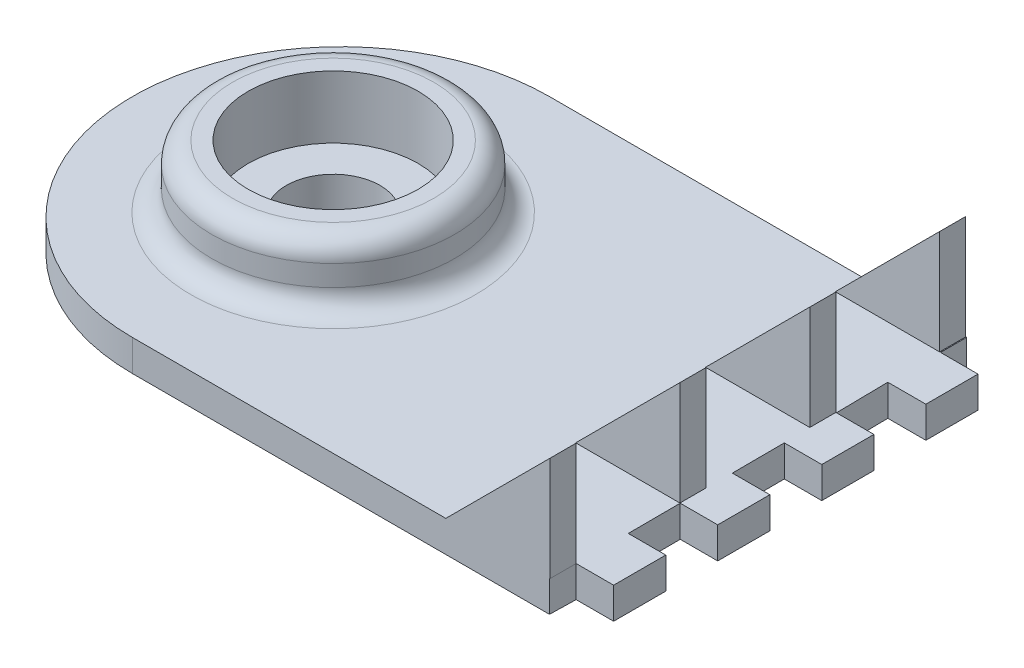
from build123d import *

# Parameters (mm, degrees)
BOSS_EXTRUDE1_DEPTH = 3
BOSS_EXTRUDE3_DEPTH = 2.5
LPATTERN2_COUNT     = 4
LPATTERN2_PITCH     = 12.5
SKETCH3_R           = 11.65
SKETCH3_R_2         = 8.15
BOSS_EXTRUDE4_DEPTH = 6
SKETCH4_R           = 4.5
CUT_EXTRUDE2_DEPTH  = 14
FILLET1_R           = 2
FILLET2_R           = 2


with BuildPart() as part:
    # Sketch1 → Boss-Extrude1 (new body)
    with BuildSketch(Plane(origin=(0, 0, 0), x_dir=(1, 0, 0), z_dir=(0, 1, 0))):
        with BuildLine():
            Line((20, 17.5), (23.592842073, 17.5))
            Line((23.592842073, 17.5), (23.592842073, 12.5))
            Line((23.592842073, 12.5), (19.944472227, 12.5))
            Line((19.944472227, 12.5), (20.019420438, 7.500018858))
            Line((20.019420438, 7.500018858), (23.612262511, 7.500018858))
            Line((23.612262511, 7.500018858), (23.612262511, 2.500018858))
            Line((23.612262511, 2.500018858), (20.019420438, 2.500018858))
            Line((20.019420438, 2.500018858), (20.038840876, -2.499962285))
            Line((20.038840876, -2.499962285), (23.63168295, -2.499962285))
            Line((23.63168295, -2.499962285), (23.63168295, -7.499962285))
            Line((23.63168295, -7.499962285), (20.038840876, -7.499962285))
            Line((20.038840876, -7.499962285), (20.058261315, -12.499943427))
            Line((20.058261315, -12.499943427), (23.651103388, -12.499943427))
            Line((23.651103388, -12.499943427), (23.651103388, -17.499943427))
            Line((23.651103388, -17.499943427), (20.058261315, -17.499943427))
            Line((20.058261315, -17.499943427), (20, -20))
            Line((20, -20), (-20, -20))
            ThreePointArc((-20, -20), (-40, 0), (-20, 20))
            Line((-20, 20), (20, 20))
            Line((20, 20), (20, 17.5))
        make_face()
    extrude(amount=BOSS_EXTRUDE1_DEPTH)

    # Sketch2 → Boss-Extrude3 (add)
    with BuildSketch(Plane.XY.offset(20)):
        Polygon((20.058261315, 3), (20.058261315, 13), (10.058261315, 3), align=None)
    boss_extrude3 = extrude(amount=-BOSS_EXTRUDE3_DEPTH)

    # LPattern2: Boss-Extrude3 ×4
    with Locations(*[Vector(-0.003884073, 0, -0.999992457) * (i * LPATTERN2_PITCH) for i in range(1, LPATTERN2_COUNT)]):
        add(boss_extrude3)

    # Sketch3 → Boss-Extrude4 (add)
    with BuildSketch(Plane(origin=(0, 3, 0), x_dir=(1, 0, 0), z_dir=(0, 1, 0))):
        with Locations((-20.741708838, 0)):
            Circle(SKETCH3_R)
        with Locations((-20.741708838, 0)):
            Circle(SKETCH3_R_2, mode=Mode.SUBTRACT)
    extrude(amount=BOSS_EXTRUDE4_DEPTH)

    # Sketch4 → Cut-Extrude2 (cut, through all)
    with BuildSketch(Plane(origin=(0, 0, 0), x_dir=(1, 0, 0), z_dir=(0, 1, 0))):
        with Locations((-20.741708838, 0)):
            Circle(SKETCH4_R)
    extrude(amount=CUT_EXTRUDE2_DEPTH, mode=Mode.SUBTRACT)

    # Fillet1
    fillet1_edges = [part.edges().sort_by_distance(p)[0] for p in [
        (-32.391708838, 3, 0),
    ]]
    fillet(fillet1_edges, radius=FILLET1_R)

    # Fillet2
    fillet2_edges = [part.edges().sort_by_distance(p)[0] for p in [
        (-32.391708838, 9, 0),
    ]]
    fillet(fillet2_edges, radius=FILLET2_R)


solid = part.part
